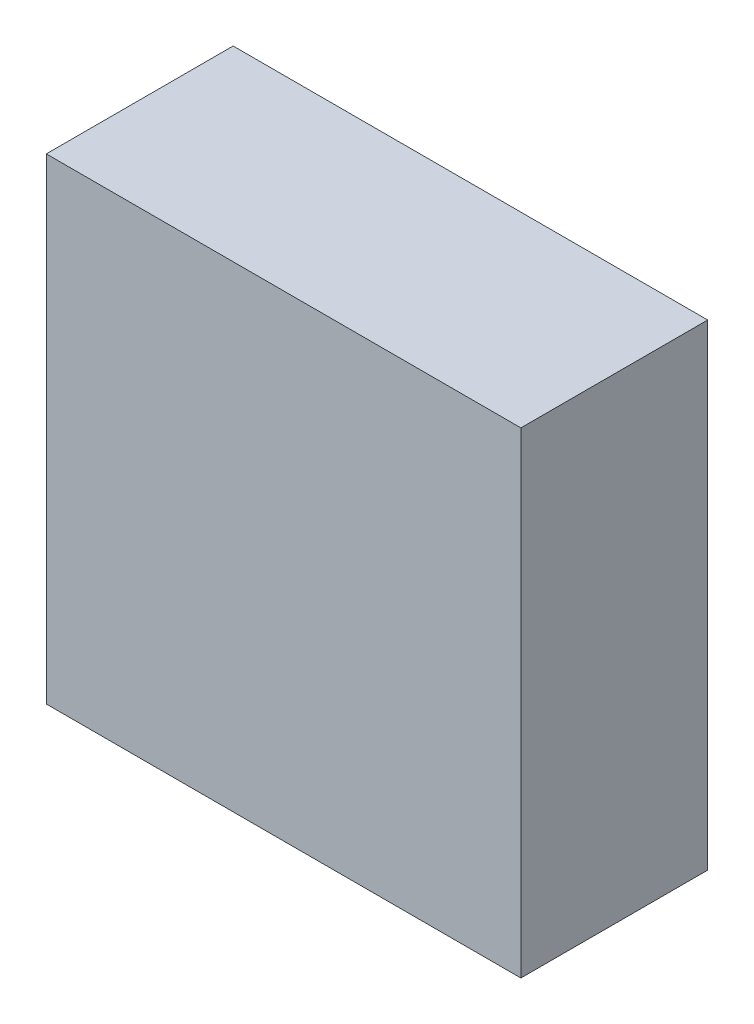
from build123d import *

# Parameters (mm, degrees)
ESQUISSE1_W        = 25.4
ESQUISSE1_H        = 25.5
BOSS_EXTRU_1_DEPTH = 10


with BuildPart() as part:
    # Esquisse1 → Boss.-Extru.1 (new body)
    with BuildSketch(Plane.XY):
        Rectangle(ESQUISSE1_W, ESQUISSE1_H)
    extrude(amount=BOSS_EXTRU_1_DEPTH)


solid = part.part
